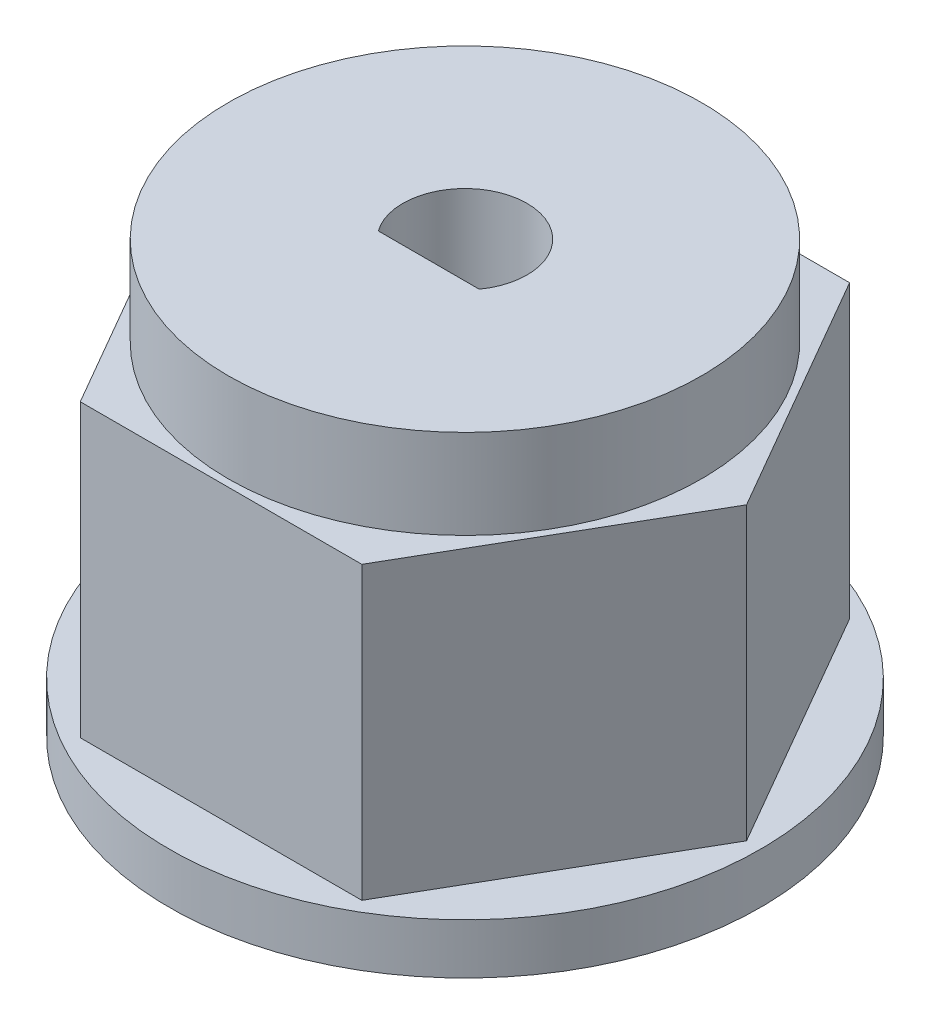
from build123d import *

# Parameters (mm, degrees)
BOSS_EXTRUDE1_DEPTH = 7.5
SKETCH2_R           = 6.1
BOSS_EXTRUDE2_DEPTH = 2.3
SKETCH3_R           = 7.625
BOSS_EXTRUDE3_DEPTH = 1.3
CUT_EXTRUDE1_DEPTH  = 12.1


with BuildPart() as part:
    # Sketch1 → Boss-Extrude1 (new body)
    with BuildSketch(Plane(origin=(0, 0, 0), x_dir=(1, 0, 0), z_dir=(0, 1, 0))):
        Polygon((7.257292884, 0), (3.628646442, 6.285), (-3.628646442, 6.285), (-7.257292884, 0), (-3.628646442, -6.285), (3.628646442, -6.285), align=None)
    extrude(amount=BOSS_EXTRUDE1_DEPTH)

    # Sketch2 → Boss-Extrude2 (add)
    with BuildSketch(Plane(origin=(0, 7.5, 0), x_dir=(1, 0, 0), z_dir=(0, 1, 0))):
        Circle(SKETCH2_R)
    extrude(amount=BOSS_EXTRUDE2_DEPTH)

    # Sketch3 → Boss-Extrude3 (add)
    with BuildSketch(Plane.XZ):
        Circle(SKETCH3_R)
    extrude(amount=BOSS_EXTRUDE3_DEPTH)

    # Sketch4 → Cut-Extrude1 (cut, through all)
    with BuildSketch(Plane(origin=(0, 9.8, 0), x_dir=(1, 0, 0), z_dir=(0, 1, 0))):
        with BuildLine():
            Line((-1.3, -0.932737905), (1.3, -0.932737905))
            ThreePointArc((1.3, -0.932737905), (0, 1.6), (-1.3, -0.932737905))
        make_face()
    extrude(amount=-CUT_EXTRUDE1_DEPTH, mode=Mode.SUBTRACT)


solid = part.part
